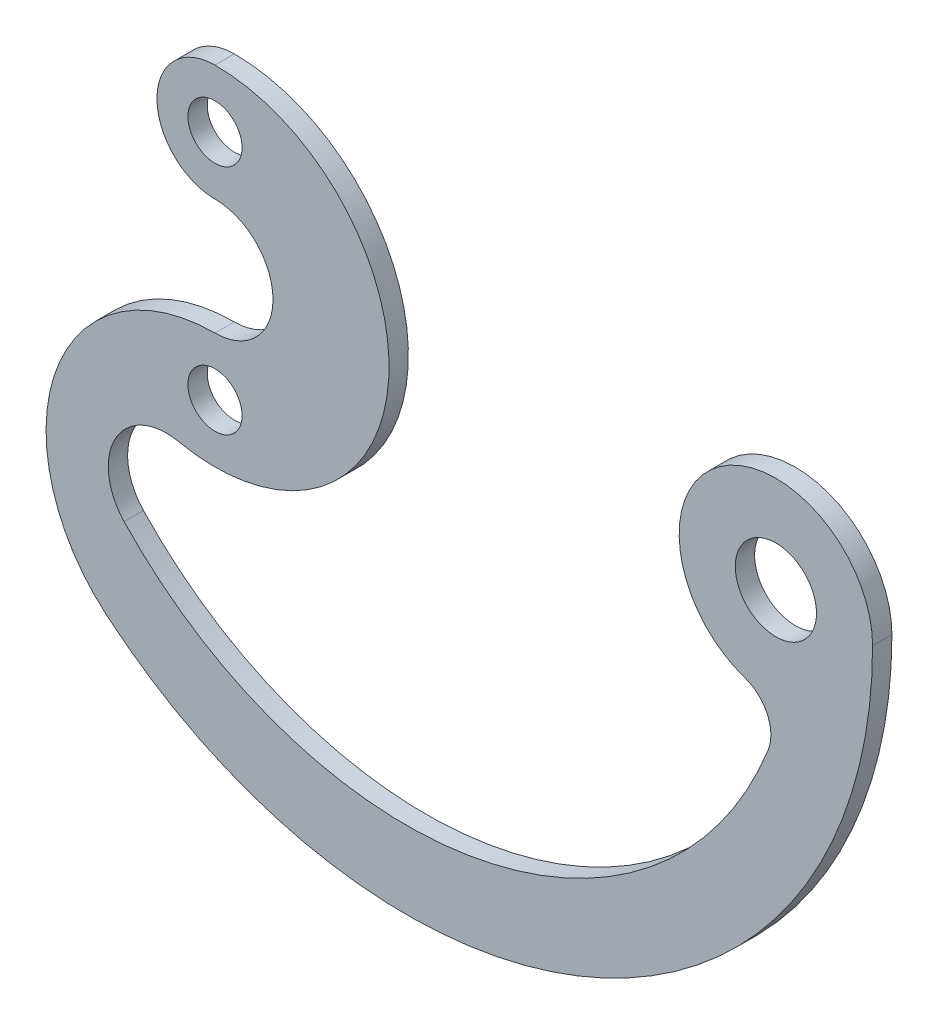
from build123d import *

# Parameters (mm, degrees)
SKETCH_1_R      = 1.4
SKETCH_1_R_2    = 2.1
EXTRUDE_1_DEPTH = 1


with BuildPart() as part:
    # 草图1 → 凸台-拉伸1 (new body)
    with BuildSketch(Plane.XY):
        with BuildLine():
            ThreePointArc((0, -3), (3, 0), (0, 3))
            ThreePointArc((0, 3), (-3, 6), (0, 9))
            ThreePointArc((0, 9), (8.949788871, -0.94935724), (-1.888121525, -8.79971574))
            ThreePointArc((-1.888121525, -8.79971574), (-5.13171085, -10.261262299), (-4.698844689, -13.792496777))
            ThreePointArc((-4.698844689, -13.792496777), (13.72027933, -19.725875002), (28.603853377, -7.358646923))
            ThreePointArc((28.603853377, -7.358646923), (28.557639821, -5.785568702), (27.387741629, -4.732929637))
            ThreePointArc((27.387741629, -4.732929637), (26.089784532, 4.065789705), (34, 0))
            ThreePointArc((34, 0), (20.055509911, -21.849807636), (-5.63484885, -18.404758393))
            ThreePointArc((-5.63484885, -18.404758393), (-8.201495332, -8.732960074), (0, -3))
        make_face()
        with Locations((0, 6)):
            Circle(SKETCH_1_R, mode=Mode.SUBTRACT)
        with Locations((0, -6)):
            Circle(SKETCH_1_R, mode=Mode.SUBTRACT)
        with Locations((29, 0)):
            Circle(SKETCH_1_R_2, mode=Mode.SUBTRACT)
    extrude(amount=EXTRUDE_1_DEPTH)


solid = part.part
